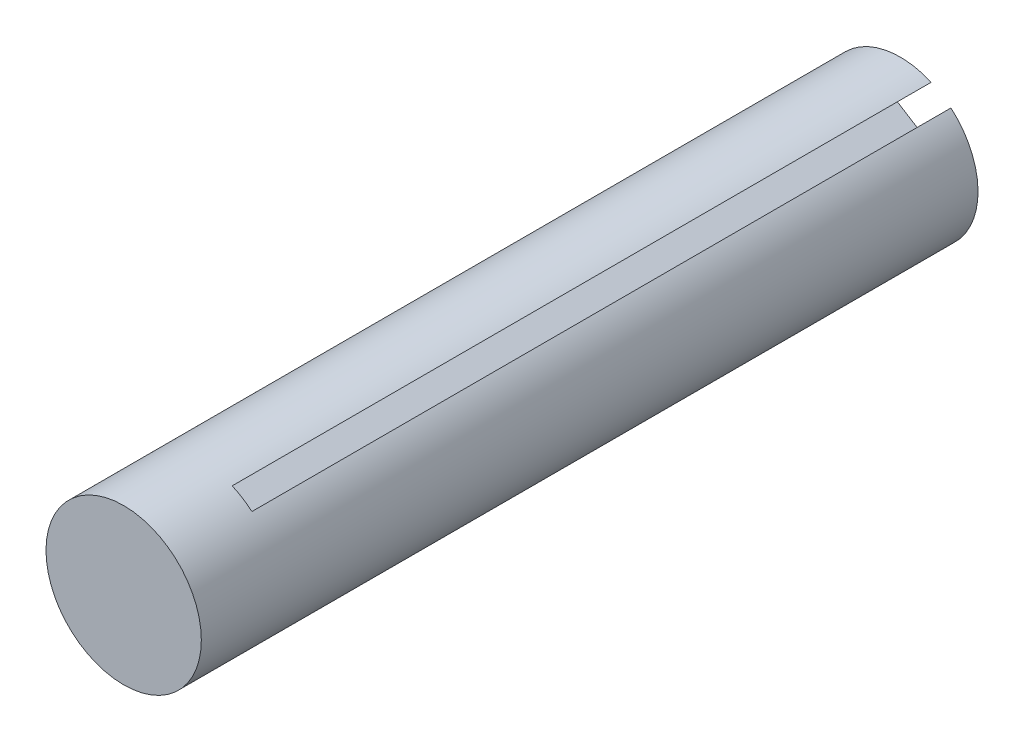
from build123d import *

# Parameters (mm, degrees)
SKETCH_1_R          = 10
EXTRUDE_1_DEPTH     = 100
SKETCH_5_R          = 1.1
CUT_EXTRUDE_3_DEPTH = 4
CUT_EXTRUDE_2_DEPTH = 90


with BuildPart() as part:
    # ｽｹｯﾁ1 → ﾎﾞｽ - 押し出し1 (new body)
    with BuildSketch(Plane.XY):
        with Locations((-5.348947677, 5.174385531)):
            Circle(SKETCH_1_R)
    extrude(amount=EXTRUDE_1_DEPTH)

    # ｽｹｯﾁ5 → ｶｯﾄ - 押し出し3 (cut)
    with BuildSketch(Plane(origin=(0, 0, 0), x_dir=(-1, 0, 0), z_dir=(0, 0, -1))):
        with Locations((5.348947677, 5.174385531)):
            Circle(SKETCH_5_R)
    extrude(amount=-CUT_EXTRUDE_3_DEPTH, mode=Mode.SUBTRACT)

    # ｽｹｯﾁ3 → ｶｯﾄ - 押し出し2 (cut)
    with BuildSketch(Plane(origin=(0, 0, 0), x_dir=(-1, 0, 0), z_dir=(0, 0, -1))):
        Polygon((9.180368817, 6.810812261), (9.286390444, 3.812686278), (9.339401258, 2.313623286), (15.282642412, 4.024729531), (17.281393068, 4.095410616), (17.175371441, 7.093536599), (15.176620785, 7.022855515), (9.127358004, 8.309875253), align=None)
        Polygon((2.016049987, 7.674280205), (4.559492439, 9.265160619), (5.831213665, 10.060600826), (1.377731611, 14.352045524), (0.317144668, 16.047673826), (-2.226297784, 14.456793412), (-1.165710841, 12.76116511), (0.74432876, 6.878839998), align=None)
        Polygon((4.850424227, 1.038064125), (2.200960148, 2.445309695), (0.876228108, 3.14893248), (-0.613530992, -2.853618463), (-1.551694705, -4.619927849), (1.097769374, -6.027173419), (2.035933088, -4.260864033), (6.175156267, 0.33444134), align=None)
    extrude(amount=-CUT_EXTRUDE_2_DEPTH, mode=Mode.SUBTRACT)


solid = part.part
